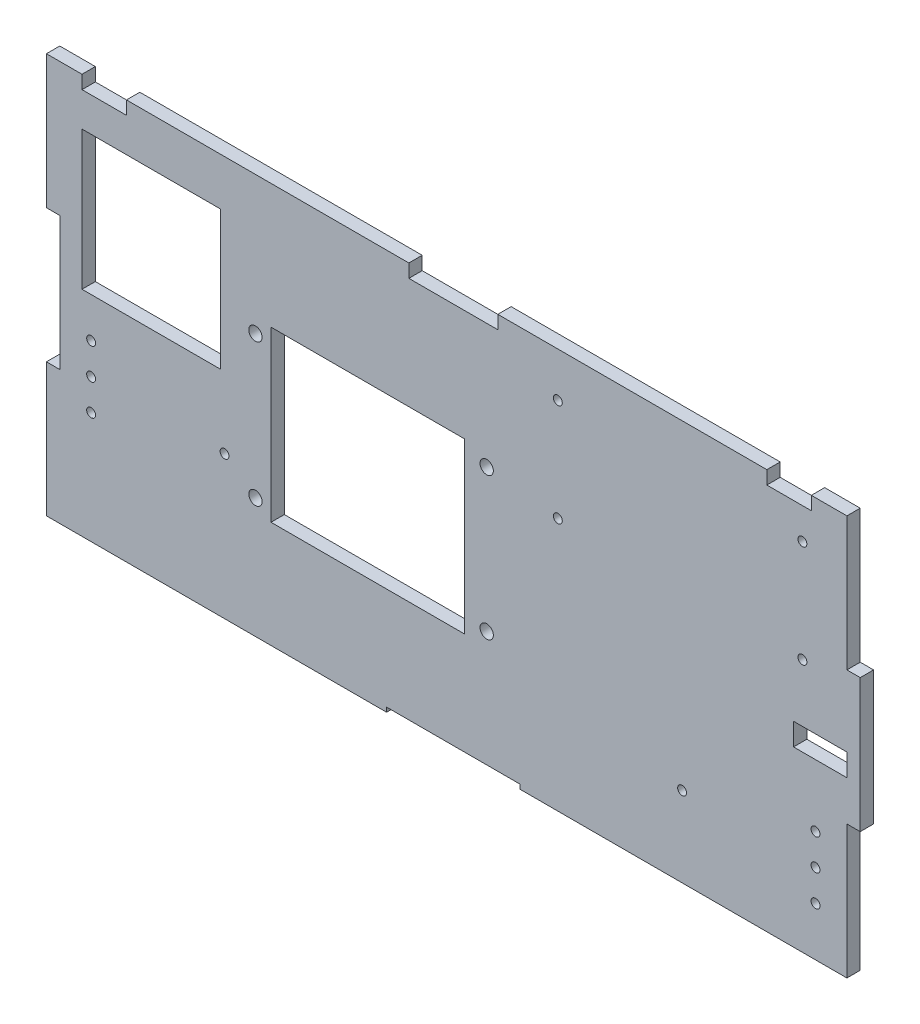
from build123d import *

# Parameters (mm, degrees)
MODEL_R             = 1
MODEL_R_2           = 1.5
MODEL_W             = 31.2
MODEL_H             = 31.2
MODEL_W_2           = 12
MODEL_H_2           = 5
MODEL_W_3           = 43.5
MODEL_H_3           = 38
BOSS_EXTRUDE1_DEPTH = 3


with BuildPart() as part:
    # Model → Boss-Extrude1 (new body)
    with BuildSketch(Plane.XY):
        Polygon((-155.141927583, -53.052781364), (-152.141927583, -53.052781364), (-152.141927583, -23.052781364), (-155.141927583, -23.052781364), (-155.141927583, 6.947218636), (-147.141927583, 6.947218636), (-147.141927583, 3.947218636), (-137.141927583, 3.947218636), (-137.141927583, 6.947218636), (-73.641927583, 6.947218636), (-73.641927583, 3.947218636), (-53.641927583, 3.947218636), (-53.641927583, 6.947218636), (6.858072417, 6.947218636), (6.858072417, 3.947218636), (16.858072417, 3.947218636), (16.858072417, 6.947218636), (24.858072417, 6.947218636), (24.858072417, -23.052781364), (27.858072417, -23.052781364), (27.858072417, -53.052781364), (24.858072417, -53.052781364), (24.858072417, -83.052781364), (-48.641927583, -83.052781364), (-48.641927583, -82.052781364), (-78.641927583, -82.052781364), (-78.641927583, -83.052781364), (-155.141927583, -83.052781364), align=None)
        with Locations((-145.091927583, -50.925083063)):
            Circle(MODEL_R, mode=Mode.SUBTRACT)
        with Locations((-115.091927583, -50.925083063)):
            Circle(MODEL_R, mode=Mode.SUBTRACT)
        with Locations((17.808072417, -65.052781364)):
            Circle(MODEL_R, mode=Mode.SUBTRACT)
        with Locations((-12.191927583, -65.052781364)):
            Circle(MODEL_R, mode=Mode.SUBTRACT)
        with Locations((-108.141927583, -24.052781364)):
            Circle(MODEL_R_2, mode=Mode.SUBTRACT)
        with Locations((-56.141927583, -24.052781364)):
            Circle(MODEL_R_2, mode=Mode.SUBTRACT)
        with Locations((-56.141927583, -56.052781364)):
            Circle(MODEL_R_2, mode=Mode.SUBTRACT)
        with Locations((-108.141927583, -56.052781364)):
            Circle(MODEL_R_2, mode=Mode.SUBTRACT)
        with Locations((17.808072417, -72.052781364)):
            Circle(MODEL_R, mode=Mode.SUBTRACT)
        with Locations((17.808072417, -58.052781364)):
            Circle(MODEL_R, mode=Mode.SUBTRACT)
        with Locations((-145.091927583, -43.925083063)):
            Circle(MODEL_R, mode=Mode.SUBTRACT)
        with Locations((-145.091927583, -57.925083063)):
            Circle(MODEL_R, mode=Mode.SUBTRACT)
        with Locations((-40.141927583, -26.052781364)):
            Circle(MODEL_R, mode=Mode.SUBTRACT)
        with Locations((14.858072417, -26.052781364)):
            Circle(MODEL_R, mode=Mode.SUBTRACT)
        with Locations((-40.141927583, -3.052781364)):
            Circle(MODEL_R, mode=Mode.SUBTRACT)
        with Locations((14.858072417, -3.052781364)):
            Circle(MODEL_R, mode=Mode.SUBTRACT)
        with Locations((-131.541927583, -19.325083063)):
            Rectangle(MODEL_W, MODEL_H, mode=Mode.SUBTRACT)
        with Locations((18.858072417, -41.552781364)):
            Rectangle(MODEL_W_2, MODEL_H_2, mode=Mode.SUBTRACT)
        with Locations((-82.891927583, -40.052781364)):
            Rectangle(MODEL_W_3, MODEL_H_3, mode=Mode.SUBTRACT)
    extrude(amount=BOSS_EXTRUDE1_DEPTH)


solid = part.part
